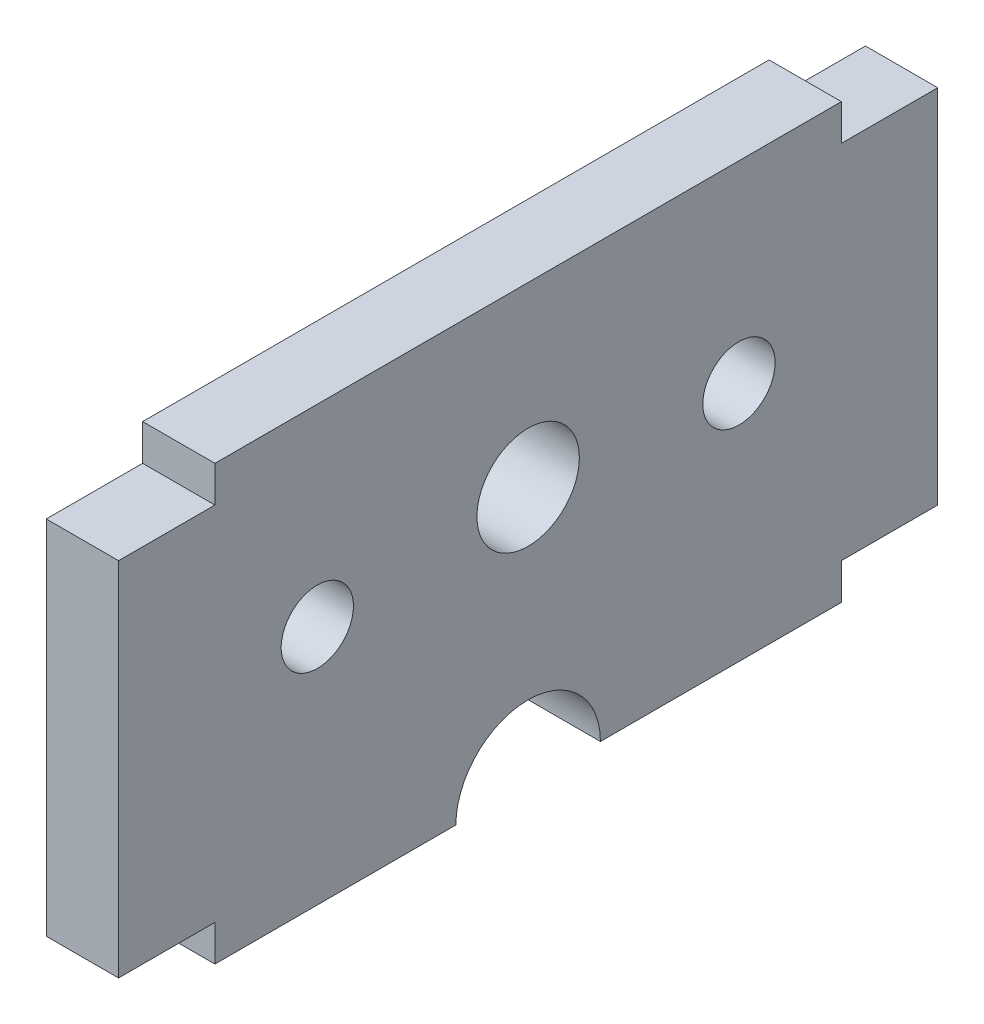
from build123d import *

# Parameters (mm, degrees)
SKETCH1_R           = 1.5
BOSS_EXTRUDE1_DEPTH = 3
CUT_EXTRUDE1_DEPTH  = 3
SKETCH3_R           = 2.125
CUT_EXTRUDE3_DEPTH  = 4


with BuildPart() as part:
    # Sketch1 → Boss-Extrude1 (new body)
    with BuildSketch(Plane(origin=(0, 0, 0), x_dir=(0, 0, -1), z_dir=(1, 0, 0))):
        Polygon((13, 6.5), (17, 6.5), (17, -8.5), (13, -8.5), (13, -10), (-13, -10), (-13, -8.5), (-17, -8.5), (-17, 6.5), (-13, 6.5), (-13, 8), (13, 8), align=None)
        with Locations((-8.75, 0)):
            Circle(SKETCH1_R, mode=Mode.SUBTRACT)
        with Locations((8.75, 0)):
            Circle(SKETCH1_R, mode=Mode.SUBTRACT)
    extrude(amount=BOSS_EXTRUDE1_DEPTH)

    # Sketch2 → Cut-Extrude1 (cut)
    with BuildSketch(Plane(origin=(3, 0, 0), x_dir=(0, 0, -1), z_dir=(1, 0, 0))):
        with BuildLine():
            Line((-3, -10), (3, -10))
            ThreePointArc((3, -10), (0, -7), (-3, -10))
        make_face()
    extrude(amount=-CUT_EXTRUDE1_DEPTH, mode=Mode.SUBTRACT)

    # Sketch3 → Cut-Extrude3 (cut, through all)
    with BuildSketch(Plane(origin=(3, 0, 0), x_dir=(0, 0, -1), z_dir=(1, 0, 0))):
        with Locations((0, 0.641129032)):
            Circle(SKETCH3_R)
    extrude(amount=-CUT_EXTRUDE3_DEPTH, mode=Mode.SUBTRACT)


solid = part.part
